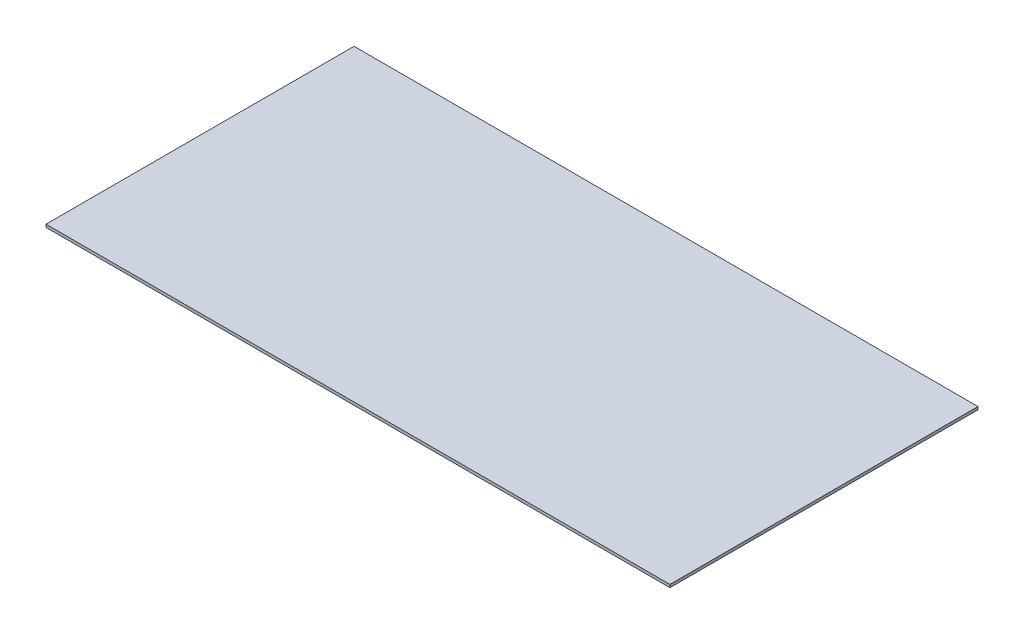
from build123d import *

# Parameters (mm, degrees)
SKETCH1_W           = 1219.2
SKETCH1_H           = 601.98
BOSS_EXTRUDE1_DEPTH = 5.55625


with BuildPart() as part:
    # Sketch1 → Boss-Extrude1 (new body)
    with BuildSketch(Plane(origin=(0, 0, 0), x_dir=(1, 0, 0), z_dir=(0, 1, 0))):
        Rectangle(SKETCH1_W, SKETCH1_H)
    extrude(amount=BOSS_EXTRUDE1_DEPTH)


solid = part.part
